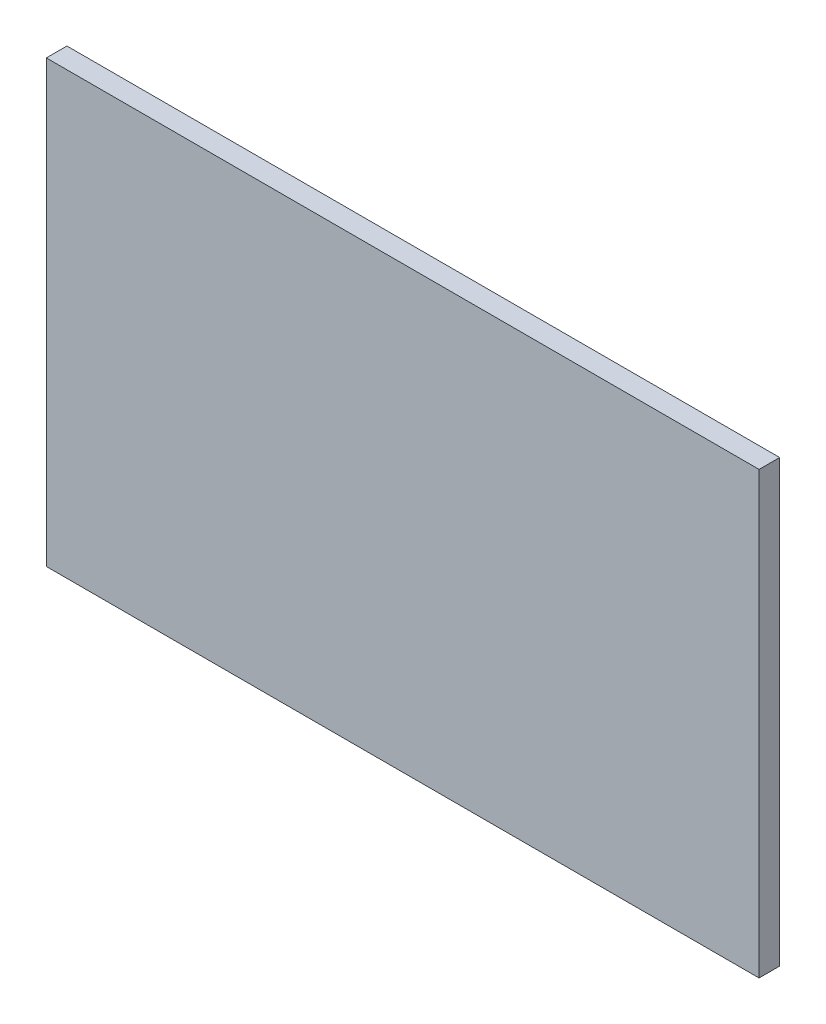
from build123d import *

# Parameters (mm, degrees)
SKETCH1_W           = 623
SKETCH1_H           = 385
BOSS_EXTRUDE1_DEPTH = 18


with BuildPart() as part:
    # Sketch1 → Boss-Extrude1 (new body)
    with BuildSketch(Plane.XY):
        Rectangle(SKETCH1_W, SKETCH1_H)
    extrude(amount=BOSS_EXTRUDE1_DEPTH)


solid = part.part
